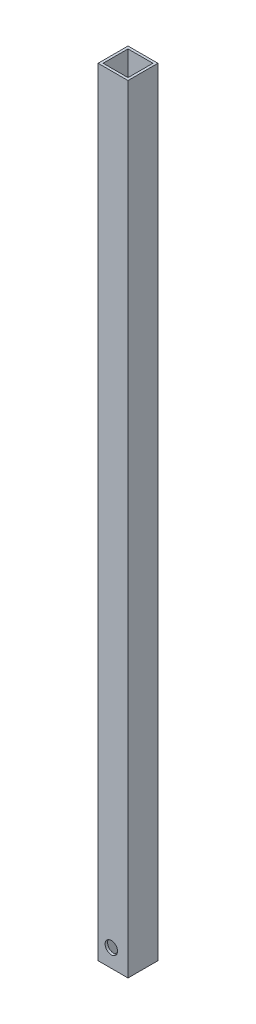
from build123d import *

# Parameters (mm, degrees)
SKETCH1_W           = 19.05
SKETCH1_H           = 19.05
SKETCH1_W_2         = 15.875
SKETCH1_H_2         = 15.875
BOSS_EXTRUDE1_DEPTH = 495.3
SKETCH2_R           = 3.96875
CUT_EXTRUDE1_DEPTH  = 1.5875
CUT_EXTRUDE2_REACH  = 21.05
SKETCH3_R           = 0.889


with BuildPart() as part:
    # Sketch1 → Boss-Extrude1 (new body)
    with BuildSketch(Plane(origin=(0, 0, 0), x_dir=(1, 0, 0), z_dir=(0, 1, 0))):
        Rectangle(SKETCH1_W, SKETCH1_H)
        Rectangle(SKETCH1_W_2, SKETCH1_H_2, mode=Mode.SUBTRACT)
    extrude(amount=BOSS_EXTRUDE1_DEPTH)

    # Sketch2 → Cut-Extrude1 (cut)
    with BuildSketch(Plane.XY.offset(9.525)):
        with Locations((-1.095375, 11.4523012)):
            Circle(SKETCH2_R)
    extrude(amount=-CUT_EXTRUDE1_DEPTH, mode=Mode.SUBTRACT)

    # Sketch3 → Cut-Extrude2 (cut, up to next)
    with BuildSketch(Plane.ZY.offset(9.525), mode=Mode.PRIVATE) as cut_extrude2_sk1:
        with Locations((0, 9.525)):
            Circle(SKETCH3_R)
    cut_extrude2_tool1 = extrude(cut_extrude2_sk1.sketch, amount=-CUT_EXTRUDE2_REACH, mode=Mode.PRIVATE) & part.part
    add(cut_extrude2_tool1.solids().sort_by_distance((-9.525, 9.525, 0))[0], mode=Mode.SUBTRACT)


solid = part.part
